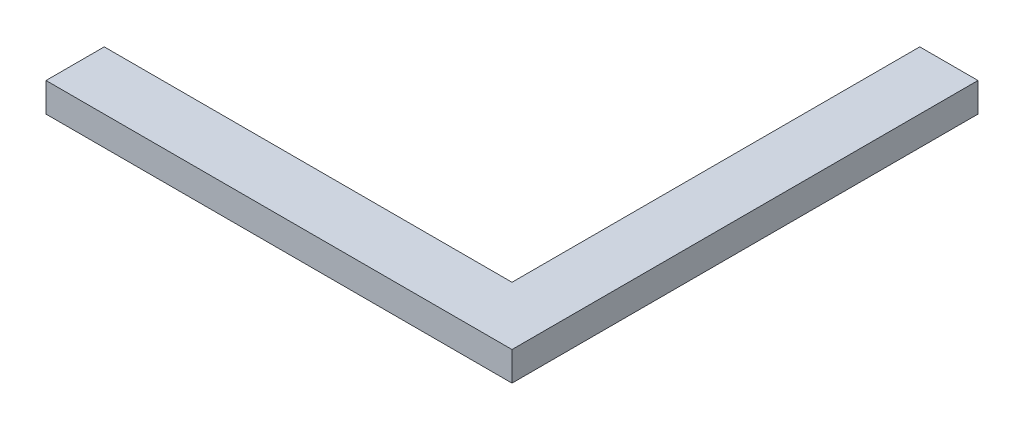
from build123d import *

# Parameters (mm, degrees)
BOSS_EXTRUDE1_DEPTH = 10


with BuildPart() as part:
    # Sketch1 → Boss-Extrude1 (new body)
    with BuildSketch(Plane(origin=(0, 0, 0), x_dir=(1, 0, 0), z_dir=(0, 1, 0))):
        Polygon((-80, -80), (80, -80), (80, 80), (60, 80), (60, -60), (-80, -60), align=None)
    extrude(amount=BOSS_EXTRUDE1_DEPTH)


solid = part.part
